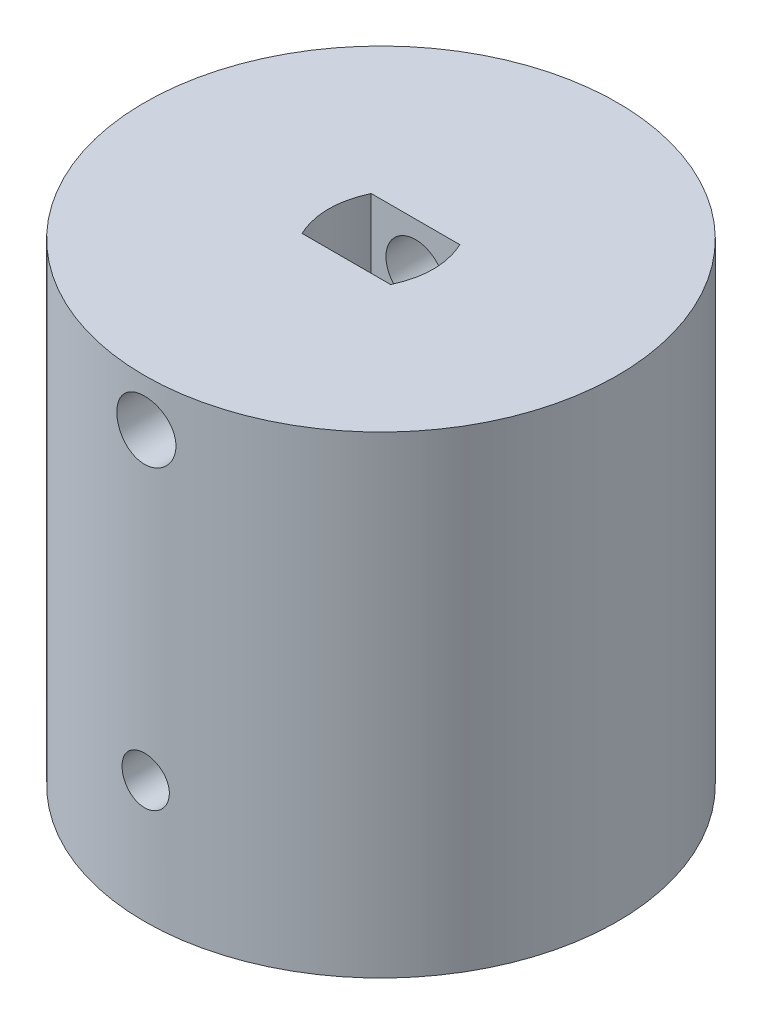
from build123d import *

# Parameters (mm, degrees)
SKETCH1_R               = 20
BOSS_EXTRUDE1_DEPTH     = 40
CUT_EXTRUDE1_DEPTH      = 15
SKETCH3_R               = 2
CUT_EXTRUDE2_DEPTH      = 15
CUT_EXTRUDE3_DEPTH      = 9
SKETCH5_R               = 2.5
CUT_EXTRUDE4_DEPTH      = 23.925000127
CUT_EXTRUDE4_DEPTH_BACK = 18.0750001
SKETCH6_W               = 10.42
SKETCH6_H               = 6.18
CUT_EXTRUDE5_DEPTH      = 15
SKETCH7_R               = 2
CUT_EXTRUDE6_DEPTH      = 15
CUT_EXTRUDE6_DEPTH_BACK = 10


with BuildPart() as part:
    # Sketch1 → Boss-Extrude1 (new body)
    with BuildSketch(Plane(origin=(0, 0, 0), x_dir=(1, 0, 0), z_dir=(0, 1, 0))):
        Circle(SKETCH1_R)
    extrude(amount=BOSS_EXTRUDE1_DEPTH)

    # Sketch2 → Cut-Extrude1 (cut)
    with BuildSketch(Plane.XZ):
        with BuildLine():
            Line((-4.000002932, 5), (3.999997068, 5))
            add(Edge.make_bspline(
                [(3.999997068, 5), (8.199974497, 0.009249301), (3.999997068, -5)],
                knots=[0, 0, 0, 1, 1, 1], degree=2))
            Line((3.999997068, -5), (-4.000002932, -5))
            add(Edge.make_bspline(
                [(-4.000002932, 5), (-8.199982148, -0.00561634), (-4.000002932, -5)],
                knots=[0, 0, 0, 1, 1, 1], degree=2))
        make_face()
    extrude(amount=-CUT_EXTRUDE1_DEPTH, mode=Mode.SUBTRACT)

    # Sketch3 → Cut-Extrude2 (cut)
    with BuildSketch(Plane.XY.offset(-5)):
        with Locations((0, 12.004234523)):
            Circle(SKETCH3_R)
    extrude(amount=-CUT_EXTRUDE2_DEPTH, mode=Mode.SUBTRACT)

    # Sketch4 → Cut-Extrude3 (cut)
    with BuildSketch(Plane(origin=(0, 40, 0), x_dir=(1, 0, 0), z_dir=(0, 1, 0))):
        with BuildLine():
            Line((-3.75, 2.925), (3.75, 2.925))
            add(Edge.make_bspline(
                [(3.75, 2.925), (5.10000002, -3.7956e-05), (3.75, -2.925)],
                knots=[0, 0, 0, 1, 1, 1], degree=2))
            Line((3.75, -2.925), (-3.75, -2.925))
            add(Edge.make_bspline(
                [(-3.75, 2.925), (-5.10000002, -3.7956e-05), (-3.75, -2.925)],
                knots=[0, 0, 0, 1, 1, 1], degree=2))
        make_face()
    extrude(amount=-CUT_EXTRUDE3_DEPTH, mode=Mode.SUBTRACT)

    # Sketch5 → Cut-Extrude4 (cut, two sides)
    with BuildSketch(Plane(origin=(0, 0, 2.925), x_dir=(-1, 0, 0), z_dir=(0, 0, -1))) as cut_extrude4_sk:
        with Locations((0, 36)):
            Circle(SKETCH5_R)
    extrude(amount=CUT_EXTRUDE4_DEPTH, mode=Mode.SUBTRACT)
    extrude(cut_extrude4_sk.sketch, amount=-CUT_EXTRUDE4_DEPTH_BACK, mode=Mode.SUBTRACT)

    # Sketch6 → Cut-Extrude5 (cut)
    with BuildSketch(Plane.XZ):
        with Locations((0, 11.59)):
            Rectangle(SKETCH6_W, SKETCH6_H)
    extrude(amount=-CUT_EXTRUDE5_DEPTH, mode=Mode.SUBTRACT)

    # Sketch7 → Cut-Extrude6 (cut, two sides)
    with BuildSketch(Plane.XY.offset(8.5)) as cut_extrude6_sk:
        with Locations((0, 10.34)):
            Circle(SKETCH7_R)
    extrude(amount=CUT_EXTRUDE6_DEPTH, mode=Mode.SUBTRACT)
    extrude(cut_extrude6_sk.sketch, amount=-CUT_EXTRUDE6_DEPTH_BACK, mode=Mode.SUBTRACT)


solid = part.part
